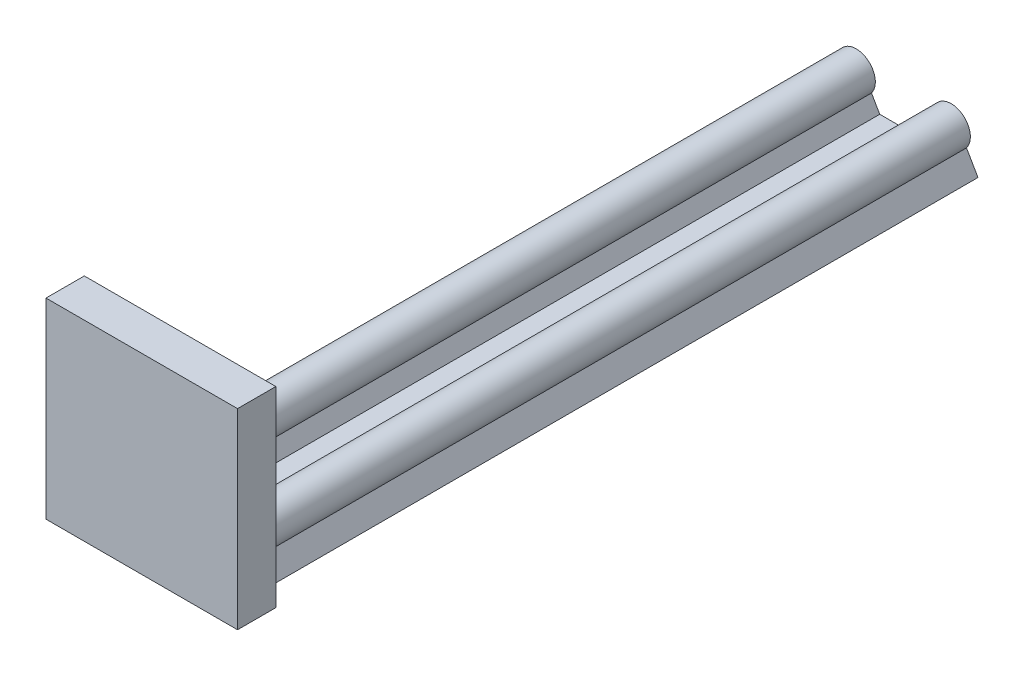
from build123d import *
from build123d.topology import SkipClean

# Parameters (mm, degrees)
BOSS_EXTRUDE1_DEPTH   = 220
BOSS_EXTRUDE1_2_DEPTH = 220
BOSS_EXTRUDE4_DEPTH   = 220
SKETCH5_R             = 1.37
CUT_EXTRUDE1_DEPTH    = 7
CUT_EXTRUDE2_START    = -7
SKETCH6_R             = 1.37
CUT_EXTRUDE2_DEPTH    = 7
CUT_EXTRUDE4_DEPTH    = 10.8
CUT_EXTRUDE5_START    = -10.8
CUT_EXTRUDE5_DEPTH    = 10.8
SKETCH11_R            = 2
CUT_EXTRUDE6_DEPTH    = 7
SKETCH12_R            = 1.5
CUT_EXTRUDE7_DEPTH    = 7
SKETCH13_W            = 50
SKETCH13_H            = 50
BOSS_EXTRUDE5_DEPTH   = 10
SKETCH14_R            = 5
CUT_EXTRUDE8_DEPTH    = 5
SKETCH4_2_R           = 3.2
CUT_EXTRUDE9_DEPTH    = 5
BOSS_EXTRUDE7_START   = 0.5
SKETCH16_R            = 1.5
BOSS_EXTRUDE7_DEPTH   = 0.5


with BuildPart() as part:
    # Sketch1 → Boss-Extrude1 (new body)
    with BuildSketch(Plane.XY):
        with BuildLine():
            Line((-4, -3), (-7, -8.196152423))
            Line((-7, -8.196152423), (7, -8.196152423))
            Line((7, -8.196152423), (4, -3))
            ThreePointArc((4, -3), (0, 5), (-4, -3))
        make_face()
    extrude(amount=BOSS_EXTRUDE1_DEPTH)



with BuildPart() as body_2:
    # Sketch1 → Boss-Extrude1 2 (new body)
    with BuildSketch(Plane.XY):
        with BuildLine():
            Line((31.8, -8.196152423), (28.8, -3))
            ThreePointArc((28.8, -3), (24.8, 5), (20.8, -3))
            Line((20.8, -3), (17.8, -8.196152423))
            Line((17.8, -8.196152423), (31.8, -8.196152423))
        make_face()
    extrude(amount=BOSS_EXTRUDE1_2_DEPTH)


with BuildPart() as part_1:
    add(part.part)

    add(body_2.part)  # Boss-Extrude4 merges body 2
    # Sketch3 → Boss-Extrude4 (add)
    with BuildSketch(Plane.XY.offset(220)):
        Polygon((7, -8.196152423), (17.8, -8.196152423), (18.65, -8.196152423), (18.65, -6.723909236), (6.15, -6.723909236), (6.15, -8.196152423), align=None)
    extrude(amount=-BOSS_EXTRUDE4_DEPTH)

    # Sketch5 → Cut-Extrude1 (cut)
    with BuildSketch(Plane(origin=(0, 0, 0), x_dir=(-1, 0, 0), z_dir=(0, 0, -1))):
        Circle(SKETCH5_R)
        with Locations((-24.8, 0)):
            Circle(SKETCH5_R)
    extrude(amount=-CUT_EXTRUDE1_DEPTH, mode=Mode.SUBTRACT)

    # Sketch6 → Cut-Extrude2 (cut)
    with BuildSketch(Plane.XY.offset(220).offset(CUT_EXTRUDE2_START)):
        Circle(SKETCH6_R)
        with Locations((24.8, 0)):
            Circle(SKETCH6_R)
    extrude(amount=CUT_EXTRUDE2_DEPTH, mode=Mode.SUBTRACT)

    # Sketch9 → Cut-Extrude4 (cut)
    with BuildSketch(Plane(origin=(0, 0, 0), x_dir=(-1, 0, 0), z_dir=(0, 0, -1))):
        with BuildLine():
            Line((-28.8, -3), (-31.8, -8.196152423))
            Line((-31.8, -8.196152423), (7, -8.196152423))
            Line((7, -8.196152423), (4, -3))
            ThreePointArc((4, -3), (0, 5), (-4, -3))
            Line((-4, -3), (-6.15, -6.723909236))
            Line((-6.15, -6.723909236), (-18.65, -6.723909236))
            Line((-18.65, -6.723909236), (-20.8, -3))
            ThreePointArc((-20.8, -3), (-24.8, 5), (-28.8, -3))
        make_face()
    extrude(amount=-CUT_EXTRUDE4_DEPTH, mode=Mode.SUBTRACT)

    # Sketch10 → Cut-Extrude5 (cut)
    with BuildSketch(Plane.XY.offset(220).offset(CUT_EXTRUDE5_START)):
        with BuildLine():
            Line((20.8, -3), (18.65, -6.723909236))
            Line((18.65, -6.723909236), (6.15, -6.723909236))
            Line((6.15, -6.723909236), (4, -3))
            ThreePointArc((4, -3), (0, 5), (-4, -3))
            Line((-4, -3), (-7, -8.196152423))
            Line((-7, -8.196152423), (31.8, -8.196152423))
            Line((31.8, -8.196152423), (28.8, -3))
            ThreePointArc((28.8, -3), (24.8, 5), (20.8, -3))
        make_face()
    extrude(amount=CUT_EXTRUDE5_DEPTH, mode=Mode.SUBTRACT)

    # Sketch11 → Cut-Extrude6 (cut)
    with BuildSketch(Plane.XY.offset(209.2)):
        Circle(SKETCH11_R)
        with Locations((24.8, 0)):
            Circle(SKETCH11_R)
    extrude(amount=-CUT_EXTRUDE6_DEPTH, mode=Mode.SUBTRACT)

    # Sketch12 → Cut-Extrude7 (cut)
    with BuildSketch(Plane(origin=(0, 0, 10.8), x_dir=(-1, 0, 0), z_dir=(0, 0, -1))):
        Circle(SKETCH12_R)
        with Locations((-24.8, 0)):
            Circle(SKETCH12_R)
    extrude(amount=-CUT_EXTRUDE7_DEPTH, mode=Mode.SUBTRACT)

    # Sketch13 → Boss-Extrude5 (add)
    with BuildSketch(Plane.XY.offset(209.2)):
        with Locations((12.4, 16.803847577)):
            Rectangle(SKETCH13_W, SKETCH13_H)
    extrude(amount=-BOSS_EXTRUDE5_DEPTH)

    # Sketch14 → Cut-Extrude8 (cut)
    with BuildSketch(Plane(origin=(0, 0, 199.2), x_dir=(-1, 0, 0), z_dir=(0, 0, -1))):
        with Locations((-12.4, 22.303847577)):
            Circle(SKETCH14_R)
    extrude(amount=-CUT_EXTRUDE8_DEPTH, mode=Mode.SUBTRACT)

    # Sketch4_2 → Cut-Extrude9 (cut)
    with BuildSketch(Plane.XZ.offset(8.196152423)):
        with Locations((0, 197.5)):
            Circle(SKETCH4_2_R)
        with Locations((24.8, 197.5)):
            Circle(SKETCH4_2_R)
        with Locations((24.8, 23.2)):
            Circle(SKETCH4_2_R)
        with Locations((0, 23.2)):
            Circle(SKETCH4_2_R)
    extrude(amount=-CUT_EXTRUDE9_DEPTH, mode=Mode.SUBTRACT)

    # Sketch16 → Boss-Extrude7 (add)
    with SkipClean():  # the faces are left unmerged after this step: merging them gives an invalid solid
        with BuildSketch(Plane(origin=(0, 0, 10.8), x_dir=(-1, 0, 0), z_dir=(0, 0, -1)).offset(BOSS_EXTRUDE7_START)):
            with BuildLine():
                Line((-28.8, -3), (-31.8, -8.196152423))
                Line((-31.8, -8.196152423), (7, -8.196152423))
                Line((7, -8.196152423), (4, -3))
                ThreePointArc((4, -3), (0, 5), (-4, -3))
                Line((-4, -3), (-6.15, -6.723909236))
                Line((-6.15, -6.723909236), (-18.65, -6.723909236))
                Line((-18.65, -6.723909236), (-20.8, -3))
                ThreePointArc((-20.8, -3), (-24.8, 5), (-28.8, -3))
            make_face()
            with Locations((-24.8, 0)):
                Circle(SKETCH16_R, mode=Mode.SUBTRACT)
            Circle(SKETCH16_R, mode=Mode.SUBTRACT)
        extrude(amount=-BOSS_EXTRUDE7_DEPTH)


solid = part_1.part
